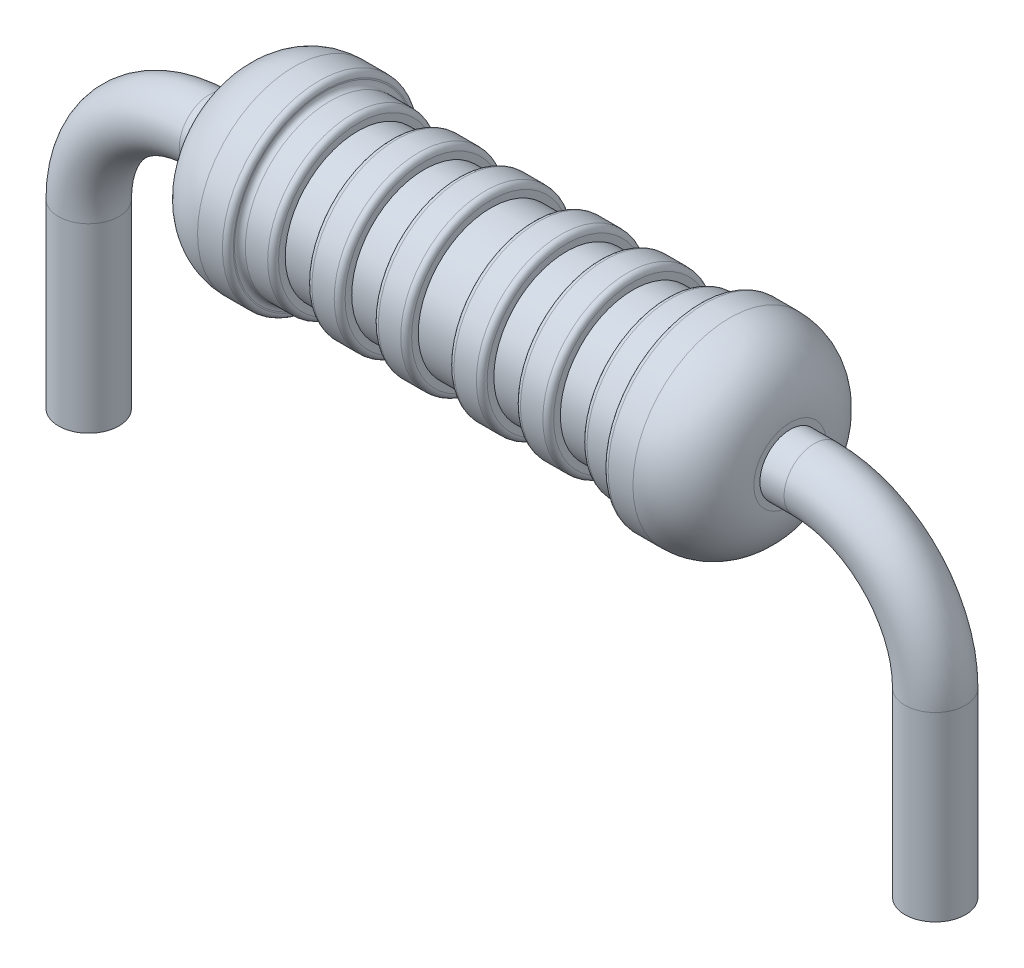
from build123d import *

# Parameters (mm, degrees)
SKETCH2_R = 0.5


with BuildPart() as part:
    # Sweep1: sweep along a path in Sketch3
    with BuildLine(Plane.XY) as sweep1_path:
        Line((7, 0), (7, 3))
        ThreePointArc((7, 3), (6.414213562, 4.414213562), (5, 5))
        Line((5, 5), (-5, 5))
        ThreePointArc((-5, 5), (-6.414213562, 4.414213562), (-7, 3))
        Line((-7, 3), (-7, 0))
    # Sketch2 → Sweep1 (sweep)
    with BuildSketch(Plane(origin=(0, 0, 0), x_dir=(1, 0, 0), z_dir=(0, 1, 0))):
        with Locations((-7, 0)):
            Circle(SKETCH2_R)
    sweep(path=sweep1_path.line)

    # Sketch4 → Revolve1 (revolve)
    with BuildSketch(Plane.XY):
        with BuildLine():
            Line((-4.6, 5), (-4.6, 4.4))
            ThreePointArc((-4.6, 4.4), (-4.307106781, 3.692893219), (-3.6, 3.4))
            Line((-3.6, 3.4), (-3.19, 3.4))
            ThreePointArc((-3.19, 3.4), (-3.12636039, 3.42636039), (-3.1, 3.49))
            Line((-3.1, 3.49), (-3.1, 3.51))
            ThreePointArc((-3.1, 3.51), (-3.07363961, 3.57363961), (-3.01, 3.6))
            Line((-3.01, 3.6), (-2.64, 3.6))
            ThreePointArc((-2.64, 3.6), (-2.57636039, 3.62636039), (-2.55, 3.69))
            Line((-2.55, 3.69), (-2.55, 3.8))
            Line((-2.55, 3.8), (-2, 3.8))
            Line((-2, 3.8), (-2, 3.69))
            ThreePointArc((-2, 3.69), (-1.97363961, 3.62636039), (-1.91, 3.6))
            Line((-1.91, 3.6), (-1.54, 3.6))
            ThreePointArc((-1.54, 3.6), (-1.47636039, 3.62636039), (-1.45, 3.69))
            Line((-1.45, 3.69), (-1.45, 3.8))
            Line((-1.45, 3.8), (-0.9, 3.8))
            Line((-0.9, 3.8), (-0.9, 3.69))
            ThreePointArc((-0.9, 3.69), (-0.87363961, 3.62636039), (-0.81, 3.6))
            Line((-0.81, 3.6), (-0.44, 3.6))
            ThreePointArc((-0.44, 3.6), (-0.37636039, 3.62636039), (-0.35, 3.69))
            Line((-0.35, 3.69), (-0.35, 3.8))
            Line((-0.35, 3.8), (0.35, 3.8))
            Line((0.35, 3.8), (0.35, 3.69))
            ThreePointArc((0.35, 3.69), (0.37636039, 3.62636039), (0.44, 3.6))
            Line((0.44, 3.6), (0.81, 3.6))
            ThreePointArc((0.81, 3.6), (0.87363961, 3.62636039), (0.9, 3.69))
            Line((0.9, 3.69), (0.9, 3.8))
            Line((0.9, 3.8), (1.45, 3.8))
            Line((1.45, 3.8), (1.45, 3.69))
            ThreePointArc((1.45, 3.69), (1.47636039, 3.62636039), (1.54, 3.6))
            Line((1.54, 3.6), (1.91, 3.6))
            ThreePointArc((1.91, 3.6), (1.97363961, 3.62636039), (2, 3.69))
            Line((2, 3.69), (2, 3.8))
            Line((2, 3.8), (2.55, 3.8))
            Line((2.55, 3.8), (2.55, 3.69))
            ThreePointArc((2.55, 3.69), (2.57636039, 3.62636039), (2.64, 3.6))
            Line((2.64, 3.6), (3.01, 3.6))
            ThreePointArc((3.01, 3.6), (3.07363961, 3.57363961), (3.1, 3.51))
            Line((3.1, 3.51), (3.1, 3.49))
            ThreePointArc((3.1, 3.49), (3.12636039, 3.42636039), (3.19, 3.4))
            Line((3.19, 3.4), (3.6, 3.4))
            ThreePointArc((3.6, 3.4), (4.307106781, 3.692893219), (4.6, 4.4))
            Line((4.6, 4.4), (4.6, 5))
            Line((4.6, 5), (-4.6, 5))
        make_face()
    revolve(axis=Axis((-4.6, 5, 0), (1, 0, 0)))


solid = part.part
